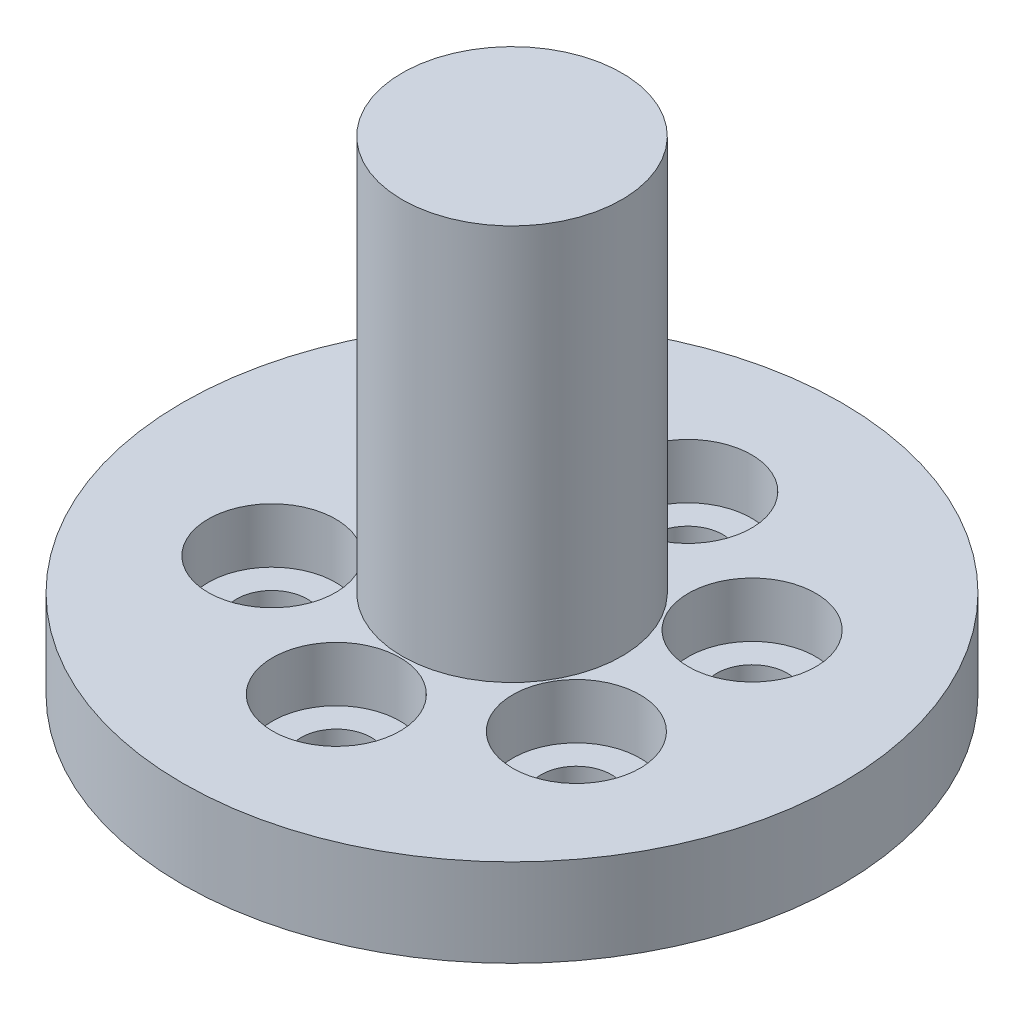
from build123d import *

# Parameters (mm, degrees)
SKETCH_1_R          = 15
EXTRUDE_1_DEPTH     = 4
SKETCH_2_R          = 1.6
CUT_EXTRUDE_1_DEPTH = 5
SKETCH_3_R          = 2.9
CUT_EXTRUDE_2_DEPTH = 2.5
SKETCH_4_R          = 5
EXTRUDE_2_DEPTH     = 18
SKETCH_5_R          = 4
CUT_EXTRUDE_3_DEPTH = 2


with BuildPart() as part:
    # 草图1 → 凸台-拉伸1 (new body)
    with BuildSketch(Plane(origin=(0, 0, 0), x_dir=(1, 0, 0), z_dir=(0, 1, 0))):
        Circle(SKETCH_1_R)
    extrude(amount=EXTRUDE_1_DEPTH)

    # 草图2 → 切除-拉伸1 (cut)
    with BuildSketch(Plane(origin=(0, 4, 0), x_dir=(1, 0, 0), z_dir=(0, 1, 0))):
        with Locations((0, 8)):
            Circle(SKETCH_2_R)
        with Locations((6.92820323, 4)):
            Circle(SKETCH_2_R)
        with Locations((6.92820323, -4)):
            Circle(SKETCH_2_R)
        with Locations((0, -8)):
            Circle(SKETCH_2_R)
        with Locations((-6.92820323, -4)):
            Circle(SKETCH_2_R)
        with Locations((-6.92820323, 4)):
            Circle(SKETCH_2_R)
    extrude(amount=-CUT_EXTRUDE_1_DEPTH, mode=Mode.SUBTRACT)

    # 草图3 → 切除-拉伸2 (cut)
    with BuildSketch(Plane(origin=(0, 4, 0), x_dir=(1, 0, 0), z_dir=(0, 1, 0))):
        with Locations((0, 8)):
            Circle(SKETCH_3_R)
        with Locations((6.92870323, 4.000866025)):
            Circle(SKETCH_3_R)
        with Locations((6.92970323, -3.999133975)):
            Circle(SKETCH_3_R)
        with Locations((0.002, -8)):
            Circle(SKETCH_3_R)
        with Locations((-6.92670323, -4.000866025)):
            Circle(SKETCH_3_R)
        with Locations((-6.92770323, 3.999133975)):
            Circle(SKETCH_3_R)
    extrude(amount=-CUT_EXTRUDE_2_DEPTH, mode=Mode.SUBTRACT)

    # 草图4 → 凸台-拉伸2 (add)
    with BuildSketch(Plane(origin=(0, 4, 0), x_dir=(1, 0, 0), z_dir=(0, 1, 0))):
        Circle(SKETCH_4_R)
    extrude(amount=EXTRUDE_2_DEPTH)

    # 草图5 → 切除-拉伸3 (cut)
    with BuildSketch(Plane.XZ):
        Circle(SKETCH_5_R)
    extrude(amount=-CUT_EXTRUDE_3_DEPTH, mode=Mode.SUBTRACT)


solid = part.part
